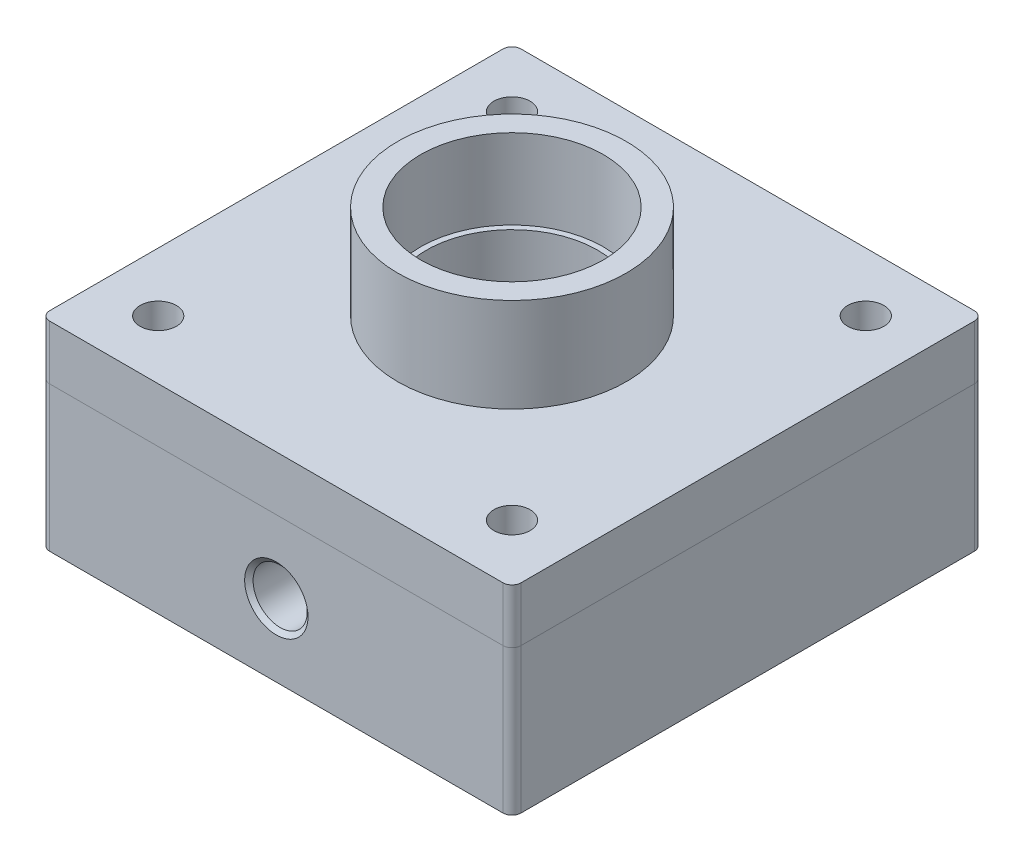
from build123d import *

# Parameters (mm, degrees)
SKETCH1_W                              = 165.1
SKETCH1_H                              = 165.1
BOSS_EXTRUDE1_DEPTH                    = 50.8
SKETCH2_R                              = 40
BOSS_EXTRUDE2_DEPTH                    = 52
SKETCH3_R                              = 32
CUT_EXTRUDE1_DEPTH                     = 28
SKETCH4_R                              = 30
CUT_EXTRUDE2_DEPTH                     = 22
FILLET1_R                              = 3.175
SKETCH5_R                              = 20
CUT_EXTRUDE3_DEPTH                     = 40
SKETCH6_R                              = 76.2
SKETCH6_R_2                            = 69.85
CUT_EXTRUDE4_DEPTH                     = 8
F_1_2_14_NPSM_TAPPED_HOLE1_D           = 18.9738
F_1_2_14_NPSM_TAPPED_HOLE1_DEPTH       = 47.24
F_1_2_14_NPSM_TAPPED_HOLE1_CSINK_D     = 22.1742
F_1_2_14_NPSM_TAPPED_HOLE1_CSINK_ANGLE = 100
F_1_2_14_NPSM_TAPPED_HOLE1_TIP         = 5.700304607
SKETCH10_R                             = 6.35
CUT_EXTRUDE5_DEPTH                     = 25
SKETCH11_R                             = 6.35
CUT_EXTRUDE6_DEPTH                     = 103.8
SKETCH13_R                             = 6.35
SKETCH13_R_2                           = 40
BOSS_EXTRUDE3_DEPTH                    = 19.05


with BuildPart() as part:
    # Sketch1 → Boss-Extrude1 (new body)
    with BuildSketch(Plane(origin=(0, 0, 0), x_dir=(1, 0, 0), z_dir=(0, 1, 0))):
        Rectangle(SKETCH1_W, SKETCH1_H)
    extrude(amount=BOSS_EXTRUDE1_DEPTH)

    # Sketch2 → Boss-Extrude2 (add)
    with BuildSketch(Plane(origin=(0, 50.8, 0), x_dir=(1, 0, 0), z_dir=(0, 1, 0))):
        Circle(SKETCH2_R)
    extrude(amount=BOSS_EXTRUDE2_DEPTH)

    # Sketch3 → Cut-Extrude1 (cut)
    with BuildSketch(Plane(origin=(0, 102.8, 0), x_dir=(1, 0, 0), z_dir=(0, 1, 0))):
        Circle(SKETCH3_R)
    extrude(amount=-CUT_EXTRUDE1_DEPTH, mode=Mode.SUBTRACT)

    # Sketch4 → Cut-Extrude2 (cut)
    with BuildSketch(Plane(origin=(0, 74.8, 0), x_dir=(1, 0, 0), z_dir=(0, 1, 0))):
        Circle(SKETCH4_R)
    extrude(amount=-CUT_EXTRUDE2_DEPTH, mode=Mode.SUBTRACT)

    # Fillet1
    fillet1_edges = [part.edges().sort_by_distance(p)[0] for p in [
        (82.55, 25.4, 82.55),
        (-82.55, 25.4, 82.55),
        (-82.55, 25.4, -82.55),
        (82.55, 25.4, -82.55),
    ]]
    fillet(fillet1_edges, radius=FILLET1_R)

    # Sketch5 → Cut-Extrude3 (cut)
    with BuildSketch(Plane.XZ):
        Circle(SKETCH5_R)
    extrude(amount=-CUT_EXTRUDE3_DEPTH, mode=Mode.SUBTRACT)

    # Sketch6 → Cut-Extrude4 (cut)
    with BuildSketch(Plane.XZ):
        Circle(SKETCH6_R)
        Circle(SKETCH6_R_2, mode=Mode.SUBTRACT)
    extrude(amount=-CUT_EXTRUDE4_DEPTH, mode=Mode.SUBTRACT)

    # 1/2-14 NPSM Tapped Hole1
    with Locations(Plane.XY.offset(82.55)):
        with Locations((0, 25.4)):
            CounterSinkHole(F_1_2_14_NPSM_TAPPED_HOLE1_D / 2, F_1_2_14_NPSM_TAPPED_HOLE1_CSINK_D / 2, depth=F_1_2_14_NPSM_TAPPED_HOLE1_DEPTH, counter_sink_angle=F_1_2_14_NPSM_TAPPED_HOLE1_CSINK_ANGLE)
            with Locations((0, 0, -(F_1_2_14_NPSM_TAPPED_HOLE1_DEPTH + F_1_2_14_NPSM_TAPPED_HOLE1_TIP / 2))):  # 118° drill point
                Cone(0, F_1_2_14_NPSM_TAPPED_HOLE1_D / 2, F_1_2_14_NPSM_TAPPED_HOLE1_TIP, mode=Mode.SUBTRACT)

    # Sketch10 → Cut-Extrude5 (cut)
    with BuildSketch(Plane.XZ):
        with Locations((0, 50.55)):
            Circle(SKETCH10_R)
    extrude(amount=-CUT_EXTRUDE5_DEPTH, mode=Mode.SUBTRACT)

    # Sketch11 → Cut-Extrude6 (cut, through all)
    with BuildSketch(Plane.XZ):
        with Locations((-61.963767235, 61.963767235)):
            Circle(SKETCH11_R)
        with Locations((61.963767235, 61.963767235)):
            Circle(SKETCH11_R)
        with Locations((61.963767235, -61.963767235)):
            Circle(SKETCH11_R)
        with Locations((-61.963767235, -61.963767235)):
            Circle(SKETCH11_R)
    extrude(amount=-CUT_EXTRUDE6_DEPTH, mode=Mode.SUBTRACT)


with BuildPart() as body_2:
    # Sketch13 → Boss-Extrude3 (new body)
    with BuildSketch(Plane(origin=(0, 50.8, 0), x_dir=(1, 0, 0), z_dir=(0, 1, 0))):
        with BuildLine():
            Line((-82.55, 79.375), (-82.55, -79.375))
            ThreePointArc((-82.55, -79.375), (-81.62006403, -81.62006403), (-79.375, -82.55))
            Line((-79.375, -82.55), (79.375, -82.55))
            ThreePointArc((79.375, -82.55), (81.62006403, -81.62006403), (82.55, -79.375))
            Line((82.55, -79.375), (82.55, 79.375))
            ThreePointArc((82.55, 79.375), (81.62006403, 81.62006403), (79.375, 82.55))
            Line((79.375, 82.55), (-79.375, 82.55))
            ThreePointArc((-79.375, 82.55), (-81.62006403, 81.62006403), (-82.55, 79.375))
        make_face()
        with Locations((61.963767235, 61.963767235)):
            Circle(SKETCH13_R, mode=Mode.SUBTRACT)
        with Locations((61.963767235, -61.963767235)):
            Circle(SKETCH13_R, mode=Mode.SUBTRACT)
        Circle(SKETCH13_R_2, mode=Mode.SUBTRACT)
        with Locations((-61.963767235, -61.963767235)):
            Circle(SKETCH13_R, mode=Mode.SUBTRACT)
        with Locations((-61.963767235, 61.963767235)):
            Circle(SKETCH13_R, mode=Mode.SUBTRACT)
    extrude(amount=BOSS_EXTRUDE3_DEPTH)


solid = Compound([part.part, body_2.part])
